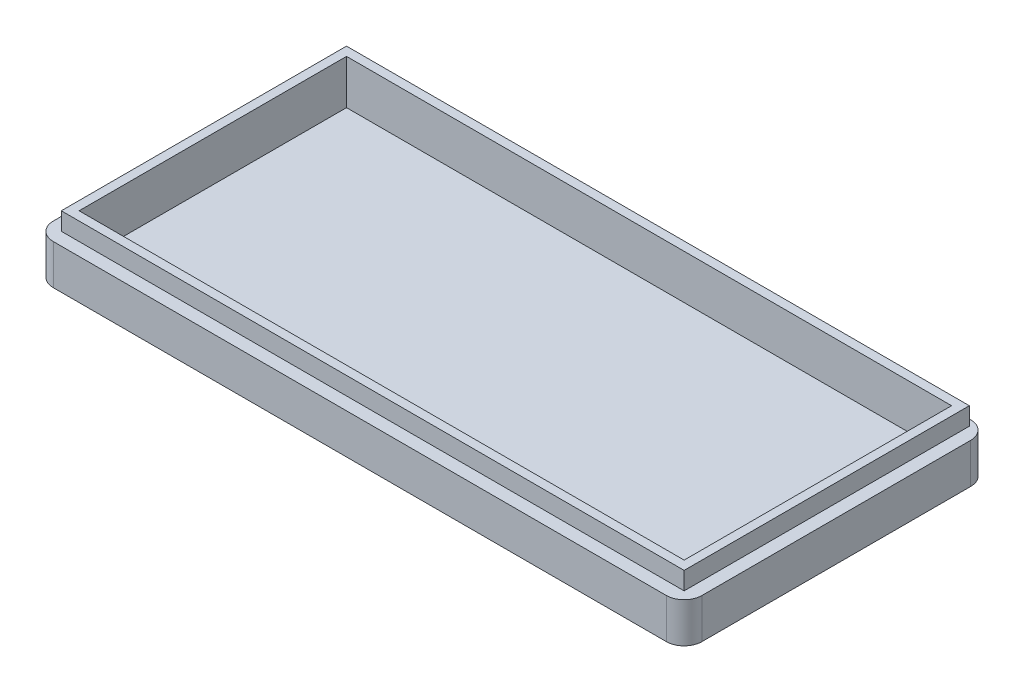
from build123d import *

# Parameters (mm, degrees)
SKETCH1_W           = 73
SKETCH1_H           = 34.25
BOSS_EXTRUDE1_DEPTH = 4.5
FILLET1_R           = 2
SKETCH2_W           = 70.1
SKETCH2_H           = 32.1
SKETCH2_W_2         = 68.1
SKETCH2_H_2         = 30.1
BOSS_EXTRUDE2_DEPTH = 2
SKETCH3_W           = 68.1
SKETCH3_H           = 30.1
CUT_EXTRUDE1_DEPTH  = 3


with BuildPart() as part:
    # Sketch1 → Boss-Extrude1 (new body)
    with BuildSketch(Plane(origin=(0, 0, 0), x_dir=(1, 0, 0), z_dir=(0, 1, 0))):
        with Locations((-0.414772727, -1.263257576)):
            Rectangle(SKETCH1_W, SKETCH1_H)
    extrude(amount=BOSS_EXTRUDE1_DEPTH)

    # Fillet1
    fillet1_edges = [part.edges().sort_by_distance(p)[0] for p in [
        (-36.914772727, 2.25, -15.861742424),
        (36.085227273, 2.25, -15.861742424),
        (36.085227273, 2.25, 18.388257576),
        (-36.914772727, 2.25, 18.388257576),
    ]]
    fillet(fillet1_edges, radius=FILLET1_R)

    # Sketch2 → Boss-Extrude2 (add)
    with BuildSketch(Plane(origin=(0, 4.5, 0), x_dir=(1, 0, 0), z_dir=(0, 1, 0))):
        with Locations((-0.414772727, -0.888257576)):
            Rectangle(SKETCH2_W, SKETCH2_H)
        with Locations((-0.414772727, -0.888257576)):
            Rectangle(SKETCH2_W_2, SKETCH2_H_2, mode=Mode.SUBTRACT)
    extrude(amount=BOSS_EXTRUDE2_DEPTH)

    # Sketch3 → Cut-Extrude1 (cut)
    with BuildSketch(Plane(origin=(0, 4.5, 0), x_dir=(1, 0, 0), z_dir=(0, 1, 0))):
        with Locations((-0.414772727, -0.888257576)):
            Rectangle(SKETCH3_W, SKETCH3_H)
    extrude(amount=-CUT_EXTRUDE1_DEPTH, mode=Mode.SUBTRACT)


solid = part.part
